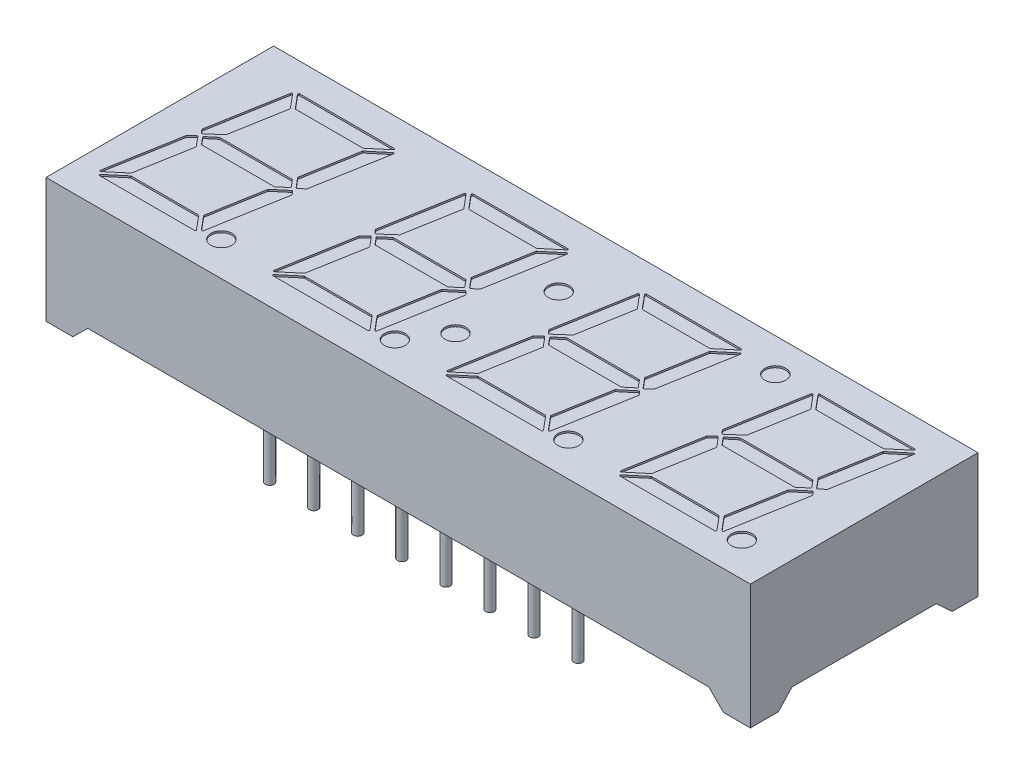
from build123d import *

# Parameters (mm, degrees)
SKETCH1_W               = 40.6
SKETCH1_H               = 7.180475014
BOSS_EXTRUDE1_DEPTH     = 13.12
CUT_EXTRUDE1_DEPTH      = 41.6
CUT_EXTRUDE1_DEPTH_BACK = 1
CUT_EXTRUDE2_DEPTH      = 14.12
SKETCH5_R               = 0.25
BOSS_EXTRUDE2_DEPTH     = 3.9
SKETCH6_R               = 0.6
CUT_EXTRUDE3_DEPTH      = 0.1
FILLET1_R               = 0.05
LPATTERN1_COUNT         = 4
LPATTERN1_PITCH         = 10
FILLET1_OF_LPATTERN1_R  = 0.05
SKETCH7_R               = 0.6
CUT_EXTRUDE4_DEPTH      = 0.1


with BuildPart() as part:
    # Sketch1 → Boss-Extrude1 (new body)
    with BuildSketch(Plane.XY):
        with Locations((20.3, 3.590237507)):
            Rectangle(SKETCH1_W, SKETCH1_H)
    extrude(amount=-BOSS_EXTRUDE1_DEPTH)

    # Sketch2 → Cut-Extrude1 (cut, two sides)
    with BuildSketch(Plane(origin=(0, 0, 0), x_dir=(0, 0, -1), z_dir=(1, 0, 0))) as cut_extrude1_sk:
        Polygon((11.631677985, 0), (1.612697573, 0), (2.4, 0.847210889), (10.72, 0.847210889), align=None)
    extrude(amount=CUT_EXTRUDE1_DEPTH, mode=Mode.SUBTRACT)
    extrude(cut_extrude1_sk.sketch, amount=-CUT_EXTRUDE1_DEPTH_BACK, mode=Mode.SUBTRACT)

    # Sketch4 → Cut-Extrude2 (cut, through all)
    with BuildSketch(Plane.XY):
        Polygon((2.4, 0.85), (38.2, 0.85), (39.05, 0), (1.55, 0), align=None)
    extrude(amount=-CUT_EXTRUDE2_DEPTH, mode=Mode.SUBTRACT)

    # Sketch5 → Boss-Extrude2 (add)
    with BuildSketch(Plane(origin=(0, 0.85, 0), x_dir=(-1, 0, 0), z_dir=(0, -1, 0))):
        with Locations((-11.41, 1.48)):
            Circle(SKETCH5_R)
        with Locations((-16.49, 1.48)):
            Circle(SKETCH5_R)
        with Locations((-19.03, 1.48)):
            Circle(SKETCH5_R)
        with Locations((-21.57, 1.48)):
            Circle(SKETCH5_R)
        with Locations((-24.11, 1.48)):
            Circle(SKETCH5_R)
        with Locations((-26.65, 1.48)):
            Circle(SKETCH5_R)
        with Locations((-29.19, 1.48)):
            Circle(SKETCH5_R)
        with Locations((-13.95, 1.48)):
            Circle(SKETCH5_R)
    boss_extrude2 = extrude(amount=BOSS_EXTRUDE2_DEPTH)

    # Mirror1: Boss-Extrude2 across plane
    add(boss_extrude2.mirror(Plane.XY.offset(-6.56)))

    # Sketch6 → Cut-Extrude3 (cut)
    with BuildSketch(Plane(origin=(0, 7.180475014, 0), x_dir=(1, 0, 0), z_dir=(0, 1, 0))):
        with Locations((8.14, 1.97)):
            Circle(SKETCH6_R)
        Polygon((7.247036913, 7.260278533), (7.750730409, 6.66), (8.091629671, 6.946048445), (8.864887741, 11.331412883), (7.808604381, 10.445085905), align=None)
        Polygon((2.296387419, 6.66), (3.059431347, 7.330570861), (3.612934542, 10.469643466), (2.869217902, 11.355970443), (2.083838107, 6.901860289), align=None)
        Polygon((6.991387513, 5.810418734), (7.76552832, 6.46), (7.964181559, 6.223254288), (7.177986185, 1.764518757), (6.434269545, 2.650845735), align=None)
        Polygon((1.945417234, 6.116836511), (1.182332886, 1.789170124), (2.238616246, 2.675497101), (2.800080915, 5.859721467), (2.296387419, 6.46), align=None)
        Polygon((3.026666473, 11.484038765), (8.73622742, 11.484038765), (7.67994406, 10.597711787), (3.766057171, 10.597711787), align=None)
        Polygon((1.310890408, 1.635961235), (7.024777297, 1.635961235), (6.281060657, 2.522288213), (2.367173768, 2.522288213), align=None)
        Polygon((7.573558914, 6.56), (7.201700594, 7.003163489), (3.001700594, 7.003163489), (2.473558914, 6.56), (2.845417234, 6.116836511), (7.045417234, 6.116836511), align=None)
    cut_extrude3 = extrude(amount=-CUT_EXTRUDE3_DEPTH, mode=Mode.SUBTRACT)

    # Fillet1
    fillet1_edges = [part.edges().sort_by_distance(p)[0] for p in [
        (3.612934542, 7.130475014, -10.469643466),
        (3.059431347, 7.130475014, -7.330570861),
        (2.296387419, 7.130475014, -6.66),
        (2.083838107, 7.130475014, -6.901860289),
        (2.869217902, 7.130475014, -11.355970443),
        (1.945417234, 7.130475014, -6.116836511),
        (2.296387419, 7.130475014, -6.46),
        (2.800080915, 7.130475014, -5.859721467),
        (2.238616246, 7.130475014, -2.675497101),
        (1.182332886, 7.130475014, -1.789170124),
        (8.73622742, 7.130475014, -11.484038765),
        (7.67994406, 7.130475014, -10.597711787),
        (3.766057171, 7.130475014, -10.597711787),
        (3.026666473, 7.130475014, -11.484038765),
        (7.177986185, 7.130475014, -1.764518757),
        (6.434269545, 7.130475014, -2.650845735),
        (6.991387513, 7.130475014, -5.810418734),
        (7.76552832, 7.130475014, -6.46),
        (7.964181559, 7.130475014, -6.223254288),
        (7.808604381, 7.130475014, -10.445085905),
        (8.864887741, 7.130475014, -11.331412883),
        (8.091629671, 7.130475014, -6.946048445),
        (7.750730409, 7.130475014, -6.66),
        (7.247036913, 7.130475014, -7.260278533),
        (7.573558914, 7.130475014, -6.56),
        (7.045417234, 7.130475014, -6.116836511),
        (2.845417234, 7.130475014, -6.116836511),
        (2.473558914, 7.130475014, -6.56),
        (3.001700594, 7.130475014, -7.003163489),
        (7.201700594, 7.130475014, -7.003163489),
        (6.281060657, 7.130475014, -2.522288213),
        (7.024777297, 7.130475014, -1.635961235),
        (1.310890408, 7.130475014, -1.635961235),
        (2.367173768, 7.130475014, -2.522288213),
    ]]
    fillet(fillet1_edges, radius=FILLET1_R)

    # LPattern1: Cut-Extrude3 ×4
    with Locations(*[(i * LPATTERN1_PITCH, 0, 0) for i in range(1, LPATTERN1_COUNT)]):
        add(cut_extrude3, mode=Mode.SUBTRACT)

    # Fillet1 of LPattern1
    fillet1_of_lpattern1_edges = [part.edges().sort_by_distance(p)[0] for p in [
        (13.612934542, 7.130475014, -10.469643466),
        (13.059431347, 7.130475014, -7.330570861),
        (12.296387419, 7.130475014, -6.66),
        (12.083838107, 7.130475014, -6.901860289),
        (12.869217902, 7.130475014, -11.355970443),
        (11.945417234, 7.130475014, -6.116836511),
        (12.296387419, 7.130475014, -6.46),
        (12.800080915, 7.130475014, -5.859721467),
        (12.238616246, 7.130475014, -2.675497101),
        (11.182332886, 7.130475014, -1.789170124),
        (18.73622742, 7.130475014, -11.484038765),
        (17.67994406, 7.130475014, -10.597711787),
        (13.766057171, 7.130475014, -10.597711787),
        (13.026666473, 7.130475014, -11.484038765),
        (17.177986185, 7.130475014, -1.764518757),
        (16.434269545, 7.130475014, -2.650845735),
        (16.991387513, 7.130475014, -5.810418734),
        (17.76552832, 7.130475014, -6.46),
        (17.964181559, 7.130475014, -6.223254288),
        (17.808604381, 7.130475014, -10.445085905),
        (18.864887741, 7.130475014, -11.331412883),
        (18.091629671, 7.130475014, -6.946048445),
        (17.750730409, 7.130475014, -6.66),
        (17.247036913, 7.130475014, -7.260278533),
        (17.573558914, 7.130475014, -6.56),
        (17.045417234, 7.130475014, -6.116836511),
        (12.845417234, 7.130475014, -6.116836511),
        (12.473558914, 7.130475014, -6.56),
        (13.001700594, 7.130475014, -7.003163489),
        (17.201700594, 7.130475014, -7.003163489),
        (16.281060657, 7.130475014, -2.522288213),
        (17.024777297, 7.130475014, -1.635961235),
        (11.310890408, 7.130475014, -1.635961235),
        (12.367173768, 7.130475014, -2.522288213),
        (23.612934542, 7.130475014, -10.469643466),
        (23.059431347, 7.130475014, -7.330570861),
        (22.296387419, 7.130475014, -6.66),
        (22.083838107, 7.130475014, -6.901860289),
        (22.869217902, 7.130475014, -11.355970443),
        (21.945417234, 7.130475014, -6.116836511),
        (22.296387419, 7.130475014, -6.46),
        (22.800080915, 7.130475014, -5.859721467),
        (22.238616246, 7.130475014, -2.675497101),
        (21.182332886, 7.130475014, -1.789170124),
        (28.73622742, 7.130475014, -11.484038765),
        (27.67994406, 7.130475014, -10.597711787),
        (23.766057171, 7.130475014, -10.597711787),
        (23.026666473, 7.130475014, -11.484038765),
        (27.177986185, 7.130475014, -1.764518757),
        (26.434269545, 7.130475014, -2.650845735),
        (26.991387513, 7.130475014, -5.810418734),
        (27.76552832, 7.130475014, -6.46),
        (27.964181559, 7.130475014, -6.223254288),
        (27.808604381, 7.130475014, -10.445085905),
        (28.864887741, 7.130475014, -11.331412883),
        (28.091629671, 7.130475014, -6.946048445),
        (27.750730409, 7.130475014, -6.66),
        (27.247036913, 7.130475014, -7.260278533),
        (27.573558914, 7.130475014, -6.56),
        (27.045417234, 7.130475014, -6.116836511),
        (22.845417234, 7.130475014, -6.116836511),
        (22.473558914, 7.130475014, -6.56),
        (23.001700594, 7.130475014, -7.003163489),
        (27.201700594, 7.130475014, -7.003163489),
        (26.281060657, 7.130475014, -2.522288213),
        (27.024777297, 7.130475014, -1.635961235),
        (21.310890408, 7.130475014, -1.635961235),
        (22.367173768, 7.130475014, -2.522288213),
        (33.612934542, 7.130475014, -10.469643466),
        (33.059431347, 7.130475014, -7.330570861),
        (32.296387419, 7.130475014, -6.66),
        (32.083838107, 7.130475014, -6.901860289),
        (32.869217902, 7.130475014, -11.355970443),
        (31.945417234, 7.130475014, -6.116836511),
        (32.296387419, 7.130475014, -6.46),
        (32.800080915, 7.130475014, -5.859721467),
        (32.238616246, 7.130475014, -2.675497101),
        (31.182332886, 7.130475014, -1.789170124),
        (38.73622742, 7.130475014, -11.484038765),
        (37.67994406, 7.130475014, -10.597711787),
        (33.766057171, 7.130475014, -10.597711787),
        (33.026666473, 7.130475014, -11.484038765),
        (37.177986185, 7.130475014, -1.764518757),
        (36.434269545, 7.130475014, -2.650845735),
        (36.991387513, 7.130475014, -5.810418734),
        (37.76552832, 7.130475014, -6.46),
        (37.964181559, 7.130475014, -6.223254288),
        (37.808604381, 7.130475014, -10.445085905),
        (38.864887741, 7.130475014, -11.331412883),
        (38.091629671, 7.130475014, -6.946048445),
        (37.750730409, 7.130475014, -6.66),
        (37.247036913, 7.130475014, -7.260278533),
        (37.573558914, 7.130475014, -6.56),
        (37.045417234, 7.130475014, -6.116836511),
        (32.845417234, 7.130475014, -6.116836511),
        (32.473558914, 7.130475014, -6.56),
        (33.001700594, 7.130475014, -7.003163489),
        (37.201700594, 7.130475014, -7.003163489),
        (36.281060657, 7.130475014, -2.522288213),
        (37.024777297, 7.130475014, -1.635961235),
        (31.310890408, 7.130475014, -1.635961235),
        (32.367173768, 7.130475014, -2.522288213),
    ]]
    fillet(fillet1_of_lpattern1_edges, radius=FILLET1_OF_LPATTERN1_R)

    # Sketch7 → Cut-Extrude4 (cut)
    with BuildSketch(Plane(origin=(0, 7.180475014, 0), x_dir=(1, 0, 0), z_dir=(0, 1, 0))):
        with Locations((20.468607364, 9.083995182)):
            Circle(SKETCH7_R)
        with Locations((19.576388019, 4.023967832)):
            Circle(SKETCH7_R)
        with Locations((30.841033019, 11.196126029)):
            Circle(SKETCH7_R)
    extrude(amount=-CUT_EXTRUDE4_DEPTH, mode=Mode.SUBTRACT)


solid = part.part
